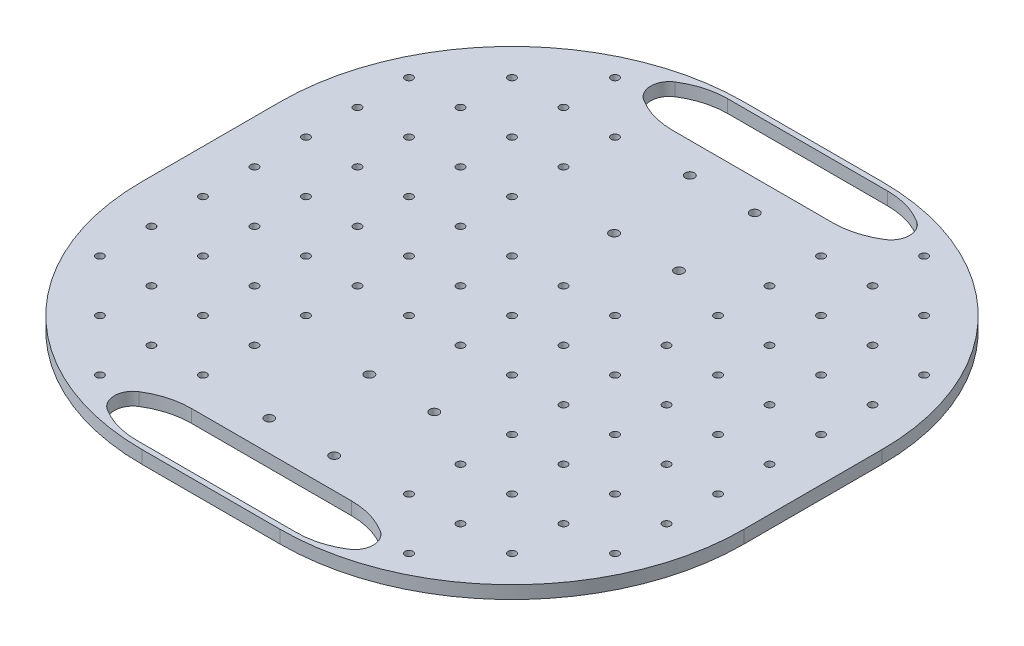
from build123d import *

# Parameters (mm, degrees)
BOSS_EXTRUDE1_DEPTH   = 6.35
CUT_EXTRUDE1_DEPTH    = 6.35
M4_CLEARANCE_HOLE1_D  = 4.5
F_6_CLEARANCE_HOLE1_D = 3.7973
F_6_CLEARANCE_HOLE2_D = 3.7973


with BuildPart() as part:
    # Sketch1 → Boss-Extrude1 (new body)
    with BuildSketch(Plane(origin=(0, 0, 0), x_dir=(1, 0, 0), z_dir=(0, 1, 0))):
        with BuildLine():
            Line((-34.13125, -148.43125), (34.13125, -148.43125))
            ThreePointArc((34.13125, -148.43125), (114.95355509, -114.95355509), (148.43125, -34.13125))
            Line((148.43125, -34.13125), (148.43125, 34.13125))
            ThreePointArc((148.43125, 34.13125), (114.95355509, 114.95355509), (34.13125, 148.43125))
            Line((34.13125, 148.43125), (-34.13125, 148.43125))
            ThreePointArc((-34.13125, 148.43125), (-114.95355509, 114.95355509), (-148.43125, 34.13125))
            Line((-148.43125, 34.13125), (-148.43125, -34.13125))
            ThreePointArc((-148.43125, -34.13125), (-114.95355509, -114.95355509), (-34.13125, -148.43125))
        make_face()
    extrude(amount=BOSS_EXTRUDE1_DEPTH)

    # Sketch4 → Cut-Extrude1 (cut)
    with BuildSketch(Plane(origin=(0, 6.35, 0), x_dir=(1, 0, 0), z_dir=(0, 1, 0))):
        with BuildLine():
            ThreePointArc((-39.448, 145.804481937), (-49.893930566, 144.330021666), (-59.523633513, 140.021852723))
            ThreePointArc((-59.523633513, 140.021852723), (-63.8175, 132.253581937), (-59.523633513, 124.485311151))
            ThreePointArc((-59.523633513, 124.485311151), (-49.893930566, 120.177142208), (-39.448, 118.702681937))
            Line((-39.448, 118.702681937), (39.448, 118.702681937))
            ThreePointArc((39.448, 118.702681937), (49.893930566, 120.177142208), (59.523633513, 124.485311151))
            ThreePointArc((59.523633513, 124.485311151), (63.8175, 132.253581937), (59.523633513, 140.021852723))
            ThreePointArc((59.523633513, 140.021852723), (49.893930566, 144.330021666), (39.448, 145.804481937))
            Line((39.448, 145.804481937), (-39.448, 145.804481937))
        make_face()
        with BuildLine():
            ThreePointArc((39.448, 120.290181937), (49.454528647, 121.702619905), (58.679163809, 125.829568258))
            ThreePointArc((58.679163809, 125.829568258), (62.23, 132.253581937), (58.679163809, 138.677595616))
            ThreePointArc((58.679163809, 138.677595616), (49.454528647, 142.804543969), (39.448, 144.216981937))
            Line((39.448, 144.216981937), (-39.448, 144.216981937))
            ThreePointArc((-39.448, 144.216981937), (-49.454528647, 142.804543969), (-58.679163809, 138.677595616))
            ThreePointArc((-58.679163809, 138.677595616), (-62.23, 132.253581937), (-58.679163809, 125.829568258))
            ThreePointArc((-58.679163809, 125.829568258), (-49.454528647, 121.702619905), (-39.448, 120.290181937))
            Line((-39.448, 120.290181937), (39.448, 120.290181937))
        make_face(mode=Mode.SUBTRACT)
        with BuildLine():
            Line((-39.448, 120.290181937), (39.448, 120.290181937))
            ThreePointArc((39.448, 120.290181937), (49.454528647, 121.702619905), (58.679163809, 125.829568258))
            ThreePointArc((58.679163809, 125.829568258), (62.23, 132.253581937), (58.679163809, 138.677595616))
            ThreePointArc((58.679163809, 138.677595616), (49.454528647, 142.804543969), (39.448, 144.216981937))
            Line((39.448, 144.216981937), (-39.448, 144.216981937))
            ThreePointArc((-39.448, 144.216981937), (-49.454528647, 142.804543969), (-58.679163809, 138.677595616))
            ThreePointArc((-58.679163809, 138.677595616), (-62.23, 132.253581937), (-58.679163809, 125.829568258))
            ThreePointArc((-58.679163809, 125.829568258), (-49.454528647, 121.702619905), (-39.448, 120.290181937))
        make_face()
        with BuildLine():
            ThreePointArc((-59.523633513, -124.485311151), (-63.8175, -132.253581937), (-59.523633513, -140.021852723))
            ThreePointArc((-59.523633513, -140.021852723), (-49.893930566, -144.330021666), (-39.448, -145.804481937))
            Line((-39.448, -145.804481937), (39.448, -145.804481937))
            ThreePointArc((39.448, -145.804481937), (49.893930566, -144.330021666), (59.523633513, -140.021852723))
            ThreePointArc((59.523633513, -140.021852723), (63.8175, -132.253581937), (59.523633513, -124.485311151))
            ThreePointArc((59.523633513, -124.485311151), (49.893930566, -120.177142208), (39.448, -118.702681937))
            Line((39.448, -118.702681937), (-39.448, -118.702681937))
            ThreePointArc((-39.448, -118.702681937), (-49.893930566, -120.177142208), (-59.523633513, -124.485311151))
        make_face()
        with BuildLine():
            ThreePointArc((-58.679163809, -138.677595616), (-49.454528647, -142.804543969), (-39.448, -144.216981937))
            Line((-39.448, -144.216981937), (39.448, -144.216981937))
            ThreePointArc((39.448, -144.216981937), (49.454528647, -142.804543969), (58.679163809, -138.677595616))
            ThreePointArc((58.679163809, -138.677595616), (62.23, -132.253581937), (58.679163809, -125.829568258))
            ThreePointArc((58.679163809, -125.829568258), (49.454528647, -121.702619905), (39.448, -120.290181937))
            Line((39.448, -120.290181937), (-39.448, -120.290181937))
            ThreePointArc((-39.448, -120.290181937), (-49.454528647, -121.702619905), (-58.679163809, -125.829568258))
            ThreePointArc((-58.679163809, -125.829568258), (-62.23, -132.253581937), (-58.679163809, -138.677595616))
        make_face(mode=Mode.SUBTRACT)
        with BuildLine():
            ThreePointArc((-58.679163809, -125.829568258), (-62.23, -132.253581937), (-58.679163809, -138.677595616))
            ThreePointArc((-58.679163809, -138.677595616), (-49.454528647, -142.804543969), (-39.448, -144.216981937))
            Line((-39.448, -144.216981937), (39.448, -144.216981937))
            ThreePointArc((39.448, -144.216981937), (49.454528647, -142.804543969), (58.679163809, -138.677595616))
            ThreePointArc((58.679163809, -138.677595616), (62.23, -132.253581937), (58.679163809, -125.829568258))
            ThreePointArc((58.679163809, -125.829568258), (49.454528647, -121.702619905), (39.448, -120.290181937))
            Line((39.448, -120.290181937), (-39.448, -120.290181937))
            ThreePointArc((-39.448, -120.290181937), (-49.454528647, -121.702619905), (-58.679163809, -125.829568258))
        make_face()
    extrude(amount=-CUT_EXTRUDE1_DEPTH, mode=Mode.SUBTRACT)

    # M4 Clearance Hole1 (through all)
    with Locations(Plane(origin=(0, 6.35, 0), x_dir=(1, 0, 0), z_dir=(0, 1, 0))):
        with Locations((-16, -103.6875), (16, -103.6875), (22, -60.325), (-10, -60.325), (-10, 60.325), (22, 60.325), (16, 103.6875), (-16, 103.6875)):
            Hole(M4_CLEARANCE_HOLE1_D / 2)

    # #6 Clearance Hole1 (through all)
    with Locations(Plane(origin=(0, 6.35, 0), x_dir=(1, 0, 0), z_dir=(0, 1, 0))):
        with Locations((-101.6, -101.6), (-101.6, 101.6), (101.6, 101.6), (101.6, -101.6), (-127, -76.2), (-127, -50.8), (-127, 50.8), (-127, 76.2), (-101.6, 76.2), (-101.6, 50.8), (-101.6, 25.4), (-101.6, 0), (-101.6, -25.4), (-101.6, -50.8), (-101.6, -76.2), (-76.2, -101.6), (-50.8, -101.6), (-50.8, -76.2), (-76.2, -76.2), (-76.2, -50.8), (-50.8, -50.8), (-50.8, -25.4), (-76.2, -25.4), (-76.2, 0), (-50.8, 0), (-50.8, 25.4), (-76.2, 25.4), (-76.2, 50.8), (-50.8, 50.8), (-50.8, 76.2), (-76.2, 76.2), (-76.2, 101.6), (-50.8, 101.6), (50.8, -101.6), (76.2, -101.6), (101.6, -76.2), (127, -76.2), (127, -50.8), (101.6, -25.4), (101.6, -50.8), (76.2, -25.4), (76.2, -50.8), (76.2, -76.2), (50.8, -76.2), (50.8, -50.8), (50.8, -25.4), (50.8, 0), (76.2, 0), (101.6, 0), (101.6, 25.4), (101.6, 50.8), (101.6, 76.2), (127, 50.8), (127, 76.2), (76.2, 101.6), (50.8, 101.6), (50.8, 76.2), (76.2, 76.2), (76.2, 50.8), (76.2, 25.4), (50.8, 25.4), (50.8, 50.8), (0, 0), (-25.4, -25.4), (-25.4, 0), (-25.4, 25.4), (0, 25.4), (25.4, 25.4), (25.4, 0), (25.4, -25.4), (0, -25.4), (127, -25.4), (127, 0), (127, 25.4), (-127, -25.4), (-127, 0), (-127, 25.4)):
            Hole(F_6_CLEARANCE_HOLE1_D / 2)

    # #6 Clearance Hole2 (through all)
    with Locations(Plane(origin=(0, 6.35, 0), x_dir=(1, 0, 0), z_dir=(0, 1, 0))):
        with Locations((-76.2, -127), (76.2, -127), (76.2, 127), (-76.2, 127)):
            Hole(F_6_CLEARANCE_HOLE2_D / 2)


solid = part.part
